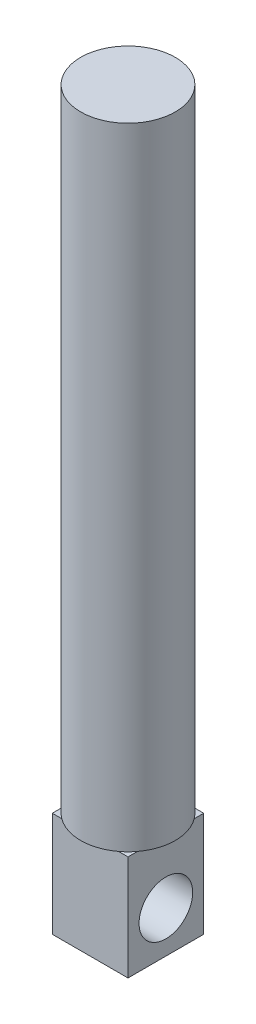
from build123d import *

# Parameters (mm, degrees)
SKETCH1_W           = 6
SKETCH1_H           = 6
BOSS_EXTRUDE1_DEPTH = 8.31
SKETCH2_R           = 2.125
CUT_EXTRUDE1_DEPTH  = 10
SKETCH3_R           = 3.75
BOSS_EXTRUDE2_DEPTH = 50


with BuildPart() as part:
    # Sketch1 → Boss-Extrude1 (new body)
    with BuildSketch(Plane(origin=(0, 0, 0), x_dir=(1, 0, 0), z_dir=(0, 1, 0))):
        with Locations((3, 3)):
            Rectangle(SKETCH1_W, SKETCH1_H)
    extrude(amount=BOSS_EXTRUDE1_DEPTH)

    # Sketch2 → Cut-Extrude1 (cut)
    with BuildSketch(Plane(origin=(6, 0, 0), x_dir=(0, 0, -1), z_dir=(1, 0, 0))):
        with Locations((3, 3.31)):
            Circle(SKETCH2_R)
    extrude(amount=-CUT_EXTRUDE1_DEPTH, mode=Mode.SUBTRACT)

    # Sketch3 → Boss-Extrude2 (add)
    with BuildSketch(Plane(origin=(0, 8.31, 0), x_dir=(1, 0, 0), z_dir=(0, 1, 0))):
        with Locations((3, 3)):
            Circle(SKETCH3_R)
    extrude(amount=BOSS_EXTRUDE2_DEPTH)


solid = part.part
